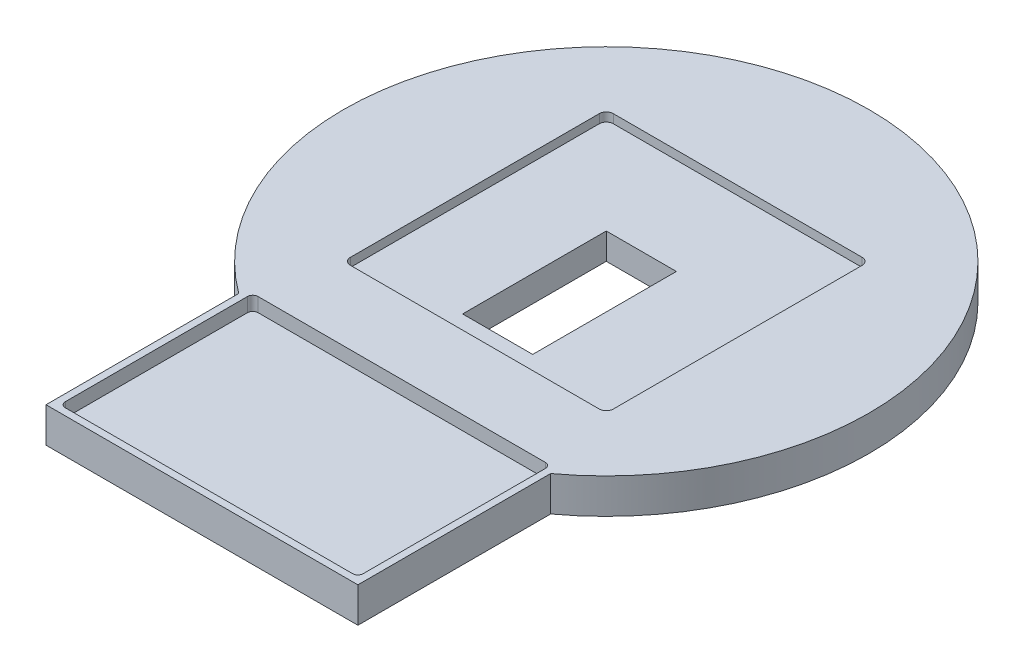
from build123d import *

# Parameters (mm, degrees)
BOSS_EXTRUDE2_DEPTH = 10
CUT_EXTRUDE2_START  = 10
SKETCH3_W           = 75
SKETCH3_H           = 75
CUT_EXTRUDE2_DEPTH  = 2.5
FILLET2_R           = 2
CUT_EXTRUDE3_START  = 10
SKETCH5_W           = 85
SKETCH5_H           = 55
CUT_EXTRUDE3_DEPTH  = 4
FILLET3_R           = 1.5
CUT_EXTRUDE4_START  = 7.5
SKETCH6_W           = 20
SKETCH6_H           = 41
CUT_EXTRUDE4_DEPTH  = 45


with BuildPart() as part:
    # Sketch2 → Boss-Extrude2 (new body)
    with BuildSketch(Plane(origin=(0, 0, 0), x_dir=(1, 0, 0), z_dir=(0, 1, 0))):
        with BuildLine():
            Line((-44.5, -60.371764924), (-44.5, -115.371764924))
            Line((-44.5, -115.371764924), (44.5, -115.371764924))
            Line((44.5, -115.371764924), (44.5, -60.371764924))
            ThreePointArc((44.5, -60.371764924), (0, 75), (-44.5, -60.371764924))
        make_face()
    extrude(amount=BOSS_EXTRUDE2_DEPTH)

    # Sketch3 → Cut-Extrude2 (cut)
    with BuildSketch(Plane(origin=(0, 0, 0), x_dir=(1, 0, 0), z_dir=(0, 1, 0)).offset(CUT_EXTRUDE2_START)):
        Rectangle(SKETCH3_W, SKETCH3_H)
    extrude(amount=-CUT_EXTRUDE2_DEPTH, mode=Mode.SUBTRACT)

    # Fillet2
    fillet2_edges = [part.edges().sort_by_distance(p)[0] for p in [
        (37.5, 8.75, -37.5),
        (37.5, 8.75, 37.5),
        (-37.5, 8.75, 37.5),
        (-37.5, 8.75, -37.5),
    ]]
    fillet(fillet2_edges, radius=FILLET2_R)

    # Sketch5 → Cut-Extrude3 (cut)
    with BuildSketch(Plane(origin=(0, 0, 0), x_dir=(1, 0, 0), z_dir=(0, 1, 0)).offset(CUT_EXTRUDE3_START)):
        with Locations((0, -85.871764924)):
            Rectangle(SKETCH5_W, SKETCH5_H)
    extrude(amount=-CUT_EXTRUDE3_DEPTH, mode=Mode.SUBTRACT)

    # Fillet3
    fillet3_edges = [part.edges().sort_by_distance(p)[0] for p in [
        (42.5, 8, 113.371764924),
        (-42.5, 8, 113.371764924),
        (-42.5, 8, 58.371764924),
        (42.5, 8, 58.371764924),
    ]]
    fillet(fillet3_edges, radius=FILLET3_R)

    # Sketch6 → Cut-Extrude4 (cut)
    with BuildSketch(Plane(origin=(0, 0, 0), x_dir=(1, 0, 0), z_dir=(0, 1, 0)).offset(CUT_EXTRUDE4_START)):
        with Locations((0, -10.5)):
            Rectangle(SKETCH6_W, SKETCH6_H)
    extrude(amount=-CUT_EXTRUDE4_DEPTH, mode=Mode.SUBTRACT)


solid = part.part
